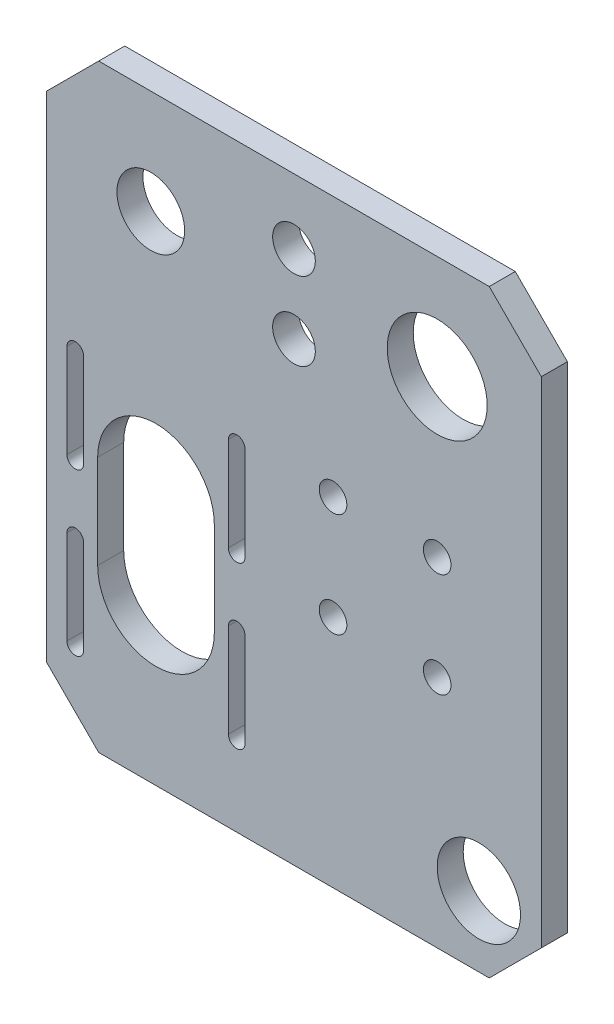
from build123d import *

# Parameters (mm, degrees)
SKETCH_1_W          = 95
SKETCH_1_H          = 75
EXTRUDE_1_DEPTH     = 5
HOLE_WIZARD_M5_1_D  = 5.3
CUT_EXTRUDE_2_DEPTH = 6
CUT_EXTRUDE_3_REACH = 7
SKETCH_4_R          = 8
SKETCH_8_W          = 95
SKETCH_8_H          = 5
EXTRUDE_2_DEPTH     = 40
CUT_EXTRUDE_4_REACH = 7
SKETCH_9_R          = 9.6
CUT_EXTRUDE_5_REACH = 7
SKETCH_10_R         = 4.1
CUT_EXTRUDE_6_REACH = 7
SKETCH_11_R         = 6.5
CHAMFER_2_SIZE      = 10


with BuildPart() as part:
    # 草圖1 → 填料-伸長1 (new body)
    with BuildSketch(Plane.XY):
        Rectangle(SKETCH_1_W, SKETCH_1_H)
    extrude(amount=EXTRUDE_1_DEPTH)

    # M5 餘隙孔1 (through all)
    with Locations(Plane.XY.offset(5)):
        with Locations((27.5, 27.5), (7.5, 7.5), (7.5, 27.5), (27.5, 7.5)):
            Hole(HOLE_WIZARD_M5_1_D / 2)

    # 草圖6 → 除料-伸長2 (cut, through all)
    with BuildSketch(Plane.XY.offset(5)):
        with BuildLine():
            Line((-37.7, -6.5), (-37.7, 11.5))
            ThreePointArc((-37.7, 11.5), (-26.5, 22.7), (-15.3, 11.5))
            Line((-15.3, 11.5), (-15.3, -6.5))
            ThreePointArc((-15.3, -6.5), (-26.5, -17.7), (-37.7, -6.5))
        make_face()
        with BuildLine():
            Line((-40.4, 27), (-40.4, 9))
            ThreePointArc((-40.4, 9), (-42, 7.4), (-43.6, 9))
            Line((-43.6, 9), (-43.6, 27))
            ThreePointArc((-43.6, 27), (-42, 28.6), (-40.4, 27))
        make_face()
        with BuildLine():
            Line((-9.4, 27), (-9.4, 9))
            ThreePointArc((-9.4, 9), (-11, 7.4), (-12.6, 9))
            Line((-12.6, 9), (-12.6, 27))
            ThreePointArc((-12.6, 27), (-11, 28.6), (-9.4, 27))
        make_face()
        with BuildLine():
            Line((-9.4, -4), (-9.4, -22))
            ThreePointArc((-9.4, -22), (-11, -23.6), (-12.6, -22))
            Line((-12.6, -22), (-12.6, -4))
            ThreePointArc((-12.6, -4), (-11, -2.4), (-9.4, -4))
        make_face()
        with BuildLine():
            Line((-40.4, -4), (-40.4, -22))
            ThreePointArc((-40.4, -22), (-42, -23.6), (-43.6, -22))
            Line((-43.6, -22), (-43.6, -4))
            ThreePointArc((-43.6, -4), (-42, -2.4), (-40.4, -4))
        make_face()
    extrude(amount=-CUT_EXTRUDE_2_DEPTH, mode=Mode.SUBTRACT)

    # 草圖4 → 除料-伸長3 (cut, up to next)
    with BuildSketch(Plane.XY.offset(5), mode=Mode.PRIVATE) as cut_extrude_3_sk1:
        with Locations((35.5, -24)):
            Circle(SKETCH_4_R)
    cut_extrude_3_tool1 = extrude(cut_extrude_3_sk1.sketch, amount=-CUT_EXTRUDE_3_REACH, mode=Mode.PRIVATE) & part.part
    add(cut_extrude_3_tool1.solids().sort_by_distance((35.5, -24, 5))[0], mode=Mode.SUBTRACT)

    # 草圖8 → 填料-伸長2 (add)
    with BuildSketch(Plane(origin=(0, 37.5, 0), x_dir=(1, 0, 0), z_dir=(0, 1, 0))):
        with Locations((0, -2.5)):
            Rectangle(SKETCH_8_W, SKETCH_8_H)
    extrude(amount=EXTRUDE_2_DEPTH)

    # 草圖9 → 除料-伸長4 (cut, up to next)
    with BuildSketch(Plane.XY.offset(5), mode=Mode.PRIVATE) as cut_extrude_4_sk1:
        with Locations((27.5, 57.5)):
            Circle(SKETCH_9_R)
    cut_extrude_4_tool1 = extrude(cut_extrude_4_sk1.sketch, amount=-CUT_EXTRUDE_4_REACH, mode=Mode.PRIVATE) & part.part
    add(cut_extrude_4_tool1.solids().sort_by_distance((27.5, 57.5, 5))[0], mode=Mode.SUBTRACT)

    # 草圖10 → 除料-伸長5 (cut, up to next)
    with BuildSketch(Plane.XY.offset(5), mode=Mode.PRIVATE) as cut_extrude_5_sk1:
        with Locations((0, 65)):
            Circle(SKETCH_10_R)
    cut_extrude_5_tool1 = extrude(cut_extrude_5_sk1.sketch, amount=-CUT_EXTRUDE_5_REACH, mode=Mode.PRIVATE) & part.part
    add(cut_extrude_5_tool1.solids().sort_by_distance((0, 65, 5))[0], mode=Mode.SUBTRACT)
    # 草圖10 → 除料-伸長5 (cut, up to next)
    with BuildSketch(Plane.XY.offset(5), mode=Mode.PRIVATE) as cut_extrude_5_sk2:
        with Locations((0, 50)):
            Circle(SKETCH_10_R)
    cut_extrude_5_tool2 = extrude(cut_extrude_5_sk2.sketch, amount=-CUT_EXTRUDE_5_REACH, mode=Mode.PRIVATE) & part.part
    add(cut_extrude_5_tool2.solids().sort_by_distance((0, 50, 5))[0], mode=Mode.SUBTRACT)

    # 草圖11 → 除料-伸長6 (cut, up to next)
    with BuildSketch(Plane.XY.offset(5), mode=Mode.PRIVATE) as cut_extrude_6_sk1:
        with Locations((-27.5, 57.5)):
            Circle(SKETCH_11_R)
    cut_extrude_6_tool1 = extrude(cut_extrude_6_sk1.sketch, amount=-CUT_EXTRUDE_6_REACH, mode=Mode.PRIVATE) & part.part
    add(cut_extrude_6_tool1.solids().sort_by_distance((-27.5, 57.5, 5))[0], mode=Mode.SUBTRACT)

    # 導角2
    chamfer_2_edges = [part.edges().sort_by_distance(p)[0] for p in [
        (47.5, 77.5, 2.5),
        (-47.5, 77.5, 2.5),
        (47.5, -37.5, 2.5),
        (-47.5, -37.5, 2.5),
    ]]
    chamfer(chamfer_2_edges, length=CHAMFER_2_SIZE)


solid = part.part
